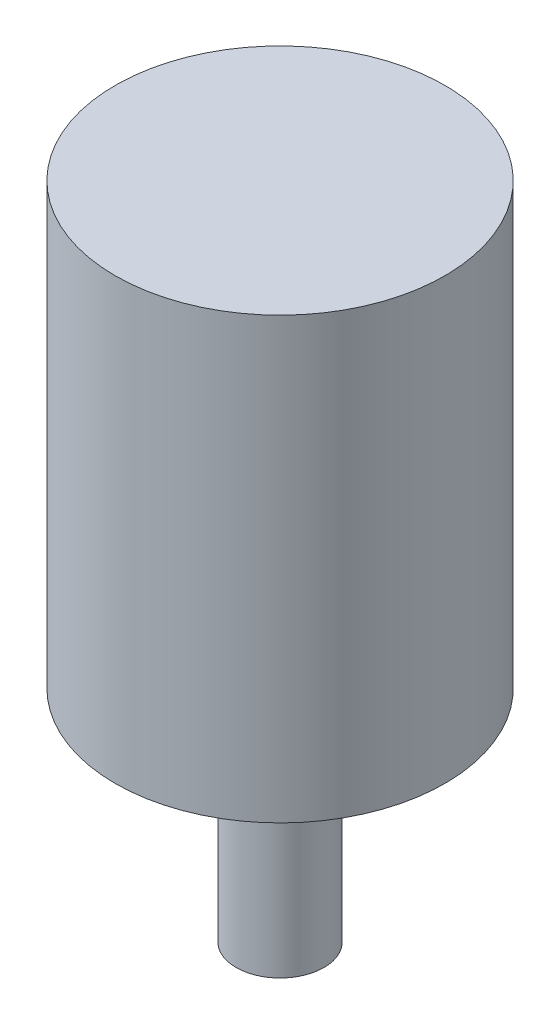
from build123d import *

# Parameters (mm, degrees)
CROQUIS1_R              = 0.375
SALIENTE_EXTRUIR1_DEPTH = 1
CROQUIS2_R              = 0.1
SALIENTE_EXTRUIR2_DEPTH = 0.5


with BuildPart() as part:
    # Croquis1 → Saliente-Extruir1 (new body)
    with BuildSketch(Plane(origin=(0, 0, 0), x_dir=(1, 0, 0), z_dir=(0, 1, 0))):
        Circle(CROQUIS1_R)
    extrude(amount=SALIENTE_EXTRUIR1_DEPTH)

    # Croquis2 → Saliente-Extruir2 (add)
    with BuildSketch(Plane(origin=(0, 0, 0), x_dir=(-1, 0, 0), z_dir=(0, -1, 0))):
        Circle(CROQUIS2_R)
    extrude(amount=SALIENTE_EXTRUIR2_DEPTH)


solid = part.part
